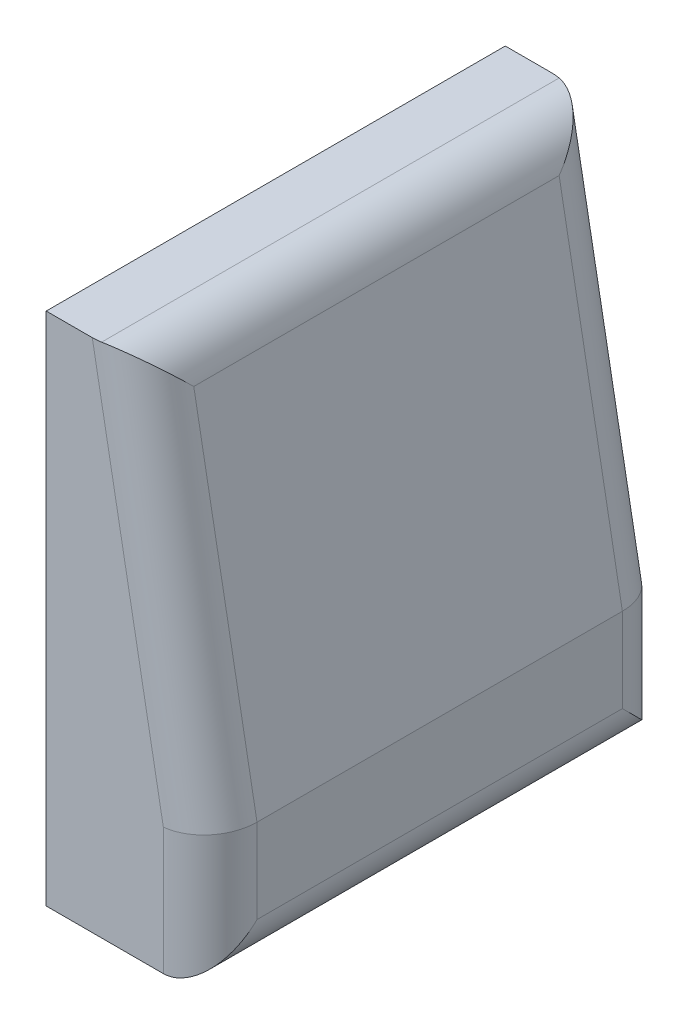
from build123d import *

# Parameters (mm, degrees)
BOSS_EXTRUDE1_DEPTH = 490
FILLET3_R           = 100


with BuildPart() as part:
    # Sketch1 → Boss-Extrude1 (new body, symmetric)
    with BuildSketch(Plane.XY):
        Polygon((0, 0), (0, 1100), (200, 1100), (350, 280), (350, 0), align=None)
    extrude(amount=BOSS_EXTRUDE1_DEPTH, both=True)

    # Fillet3
    fillet3_edges = [part.edges().sort_by_distance(p)[0] for p in [
        (275, 690, 490),
        (275, 690, -490),
        (350, 140, -490),
        (350, 140, 490),
        (200, 1100, 0),
        (350, 0, 0),
    ]]
    fillet(fillet3_edges, radius=FILLET3_R)


solid = part.part
